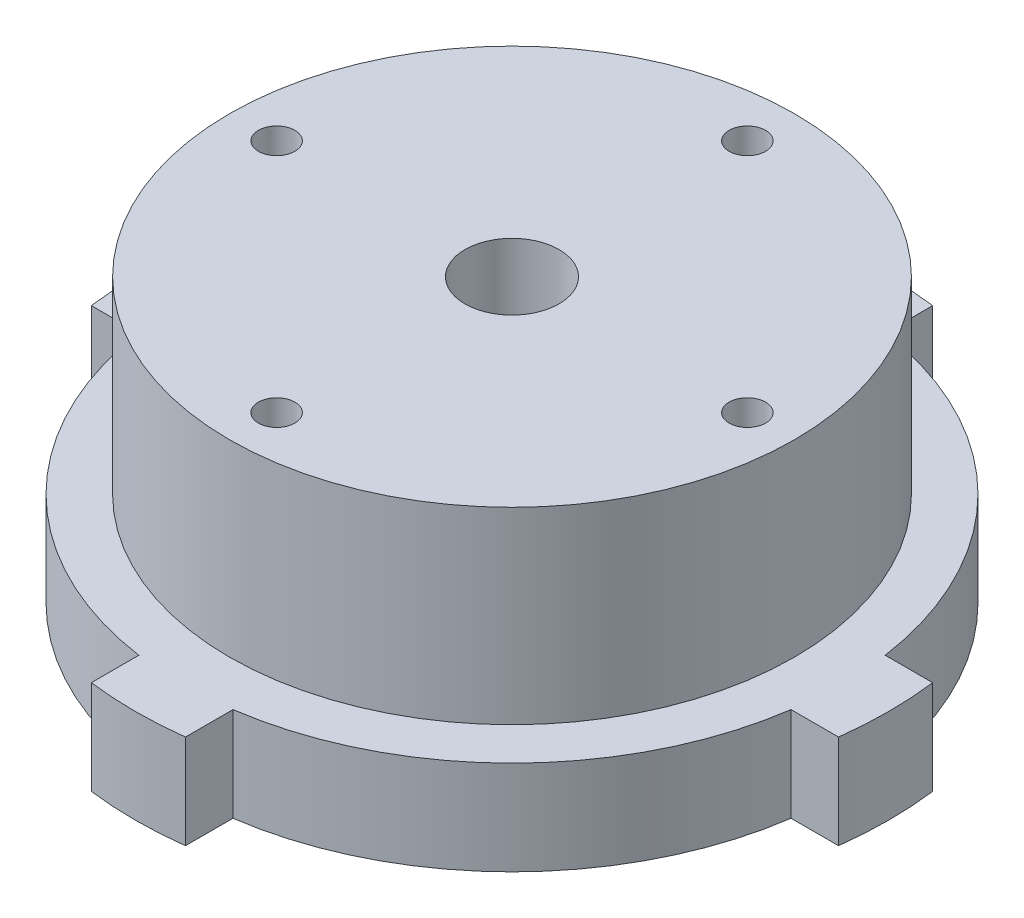
from build123d import *

# Parameters (mm, degrees)
SKETCH2_R                    = 38.1
SKETCH2_R_2                  = 6.35
BOSS_EXTRUDE2_DEPTH          = 25.4
BOSS_EXTRUDE3_START          = -12.7
SKETCH2_5_R                  = 6.35
BOSS_EXTRUDE3_DEPTH          = 12.7
F_10_0_1935_DIAMETER_HOLE2_D = 4.9149
CIRPATTERN2_COUNT            = 4


with BuildPart() as part:
    # Sketch2 → Boss-Extrude2 (new body)
    with BuildSketch(Plane(origin=(0, 0, 0), x_dir=(1, 0, 0), z_dir=(0, 1, 0))):
        Circle(SKETCH2_R)
        Circle(SKETCH2_R_2, mode=Mode.SUBTRACT)
    extrude(amount=BOSS_EXTRUDE2_DEPTH)

    # Sketch2_5 → Boss-Extrude3 (add)
    with BuildSketch(Plane(origin=(0, 0, 0), x_dir=(1, 0, 0), z_dir=(0, 1, 0)).offset(BOSS_EXTRUDE3_START)):
        with BuildLine():
            Line((-6.35, 50.401562476), (-6.35, 43.994090512))
            ThreePointArc((-6.35, 43.994090512), (-31.430896424, 31.430896424), (-43.994090512, 6.35))
            Line((-43.994090512, 6.35), (-50.401562476, 6.35))
            ThreePointArc((-50.401562476, 6.35), (-50.8, 0), (-50.401562476, -6.35))
            Line((-50.401562476, -6.35), (-43.994090512, -6.35))
            ThreePointArc((-43.994090512, -6.35), (-31.430896424, -31.430896424), (-6.35, -43.994090512))
            Line((-6.35, -43.994090512), (-6.35, -50.401562476))
            ThreePointArc((-6.35, -50.401562476), (0, -50.8), (6.35, -50.401562476))
            Line((6.35, -50.401562476), (6.35, -43.994090512))
            ThreePointArc((6.35, -43.994090512), (31.430896424, -31.430896424), (43.994090512, -6.35))
            Line((43.994090512, -6.35), (50.401562476, -6.35))
            ThreePointArc((50.401562476, -6.35), (50.8, 0), (50.401562476, 6.35))
            Line((50.401562476, 6.35), (43.994090512, 6.35))
            ThreePointArc((43.994090512, 6.35), (31.430896424, 31.430896424), (6.35, 43.994090512))
            Line((6.35, 43.994090512), (6.35, 50.401562476))
            ThreePointArc((6.35, 50.401562476), (0, 50.8), (-6.35, 50.401562476))
        make_face()
        Circle(SKETCH2_5_R, mode=Mode.SUBTRACT)
    extrude(amount=BOSS_EXTRUDE3_DEPTH)

    # 10 _0.1935_ Diameter Hole2 (through all)
    with Locations(Plane(origin=(0, -12.7, 31.75), x_dir=(0, 0, -1), z_dir=(0, -1, 0))):
        with Locations((0, 0)):
            f_10_0_1935_diameter_hole2 = Hole(F_10_0_1935_DIAMETER_HOLE2_D / 2)

    # CirPattern2: 10 _0.1935_ Diameter Hole2 ×4 about axis
    cirpattern2_axis = Axis((0, 25.4, 0), (0, -1, 0))
    for i in range(1, CIRPATTERN2_COUNT):
        add(f_10_0_1935_diameter_hole2.rotate(cirpattern2_axis, i * 360 / CIRPATTERN2_COUNT), mode=Mode.SUBTRACT)


solid = part.part
